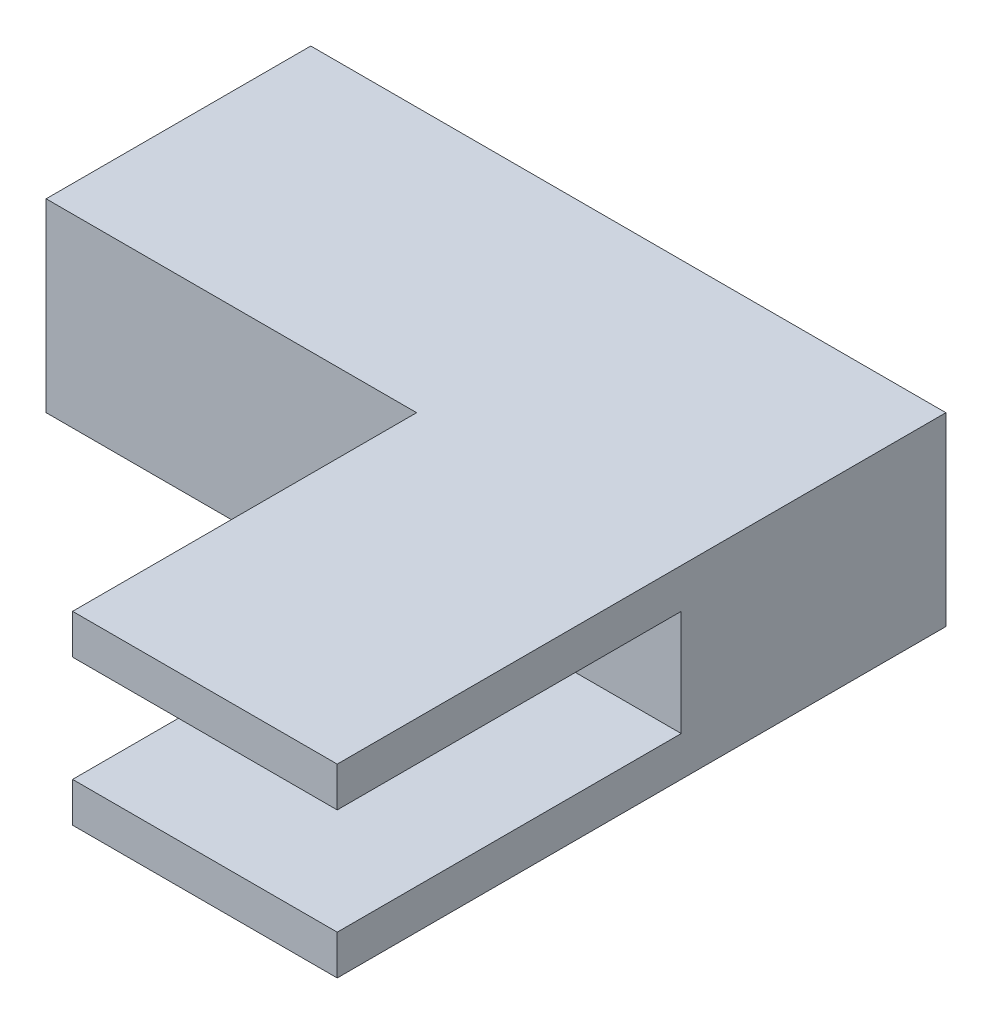
from build123d import *

# Parameters (mm, degrees)
BOSS_EXTRUDE2_DEPTH = 7
SKETCH4_W           = 24
SKETCH4_H           = 4
CUT_EXTRUDE1_DEPTH  = 13


with BuildPart() as part:
    # Sketch3 → Boss-Extrude2 (new body)
    with BuildSketch(Plane(origin=(0, 0, 0), x_dir=(1, 0, 0), z_dir=(0, 1, 0))):
        Polygon((12, 11.5), (-12, 11.5), (-12, 1.5), (2, 1.5), (2, -11.5), (12, -11.5), align=None)
    extrude(amount=-BOSS_EXTRUDE2_DEPTH)

    # Sketch4 → Cut-Extrude1 (cut)
    with BuildSketch(Plane.XY.offset(11.5)):
        with Locations((0, -3.5)):
            Rectangle(SKETCH4_W, SKETCH4_H)
    extrude(amount=-CUT_EXTRUDE1_DEPTH, mode=Mode.SUBTRACT)


solid = part.part
